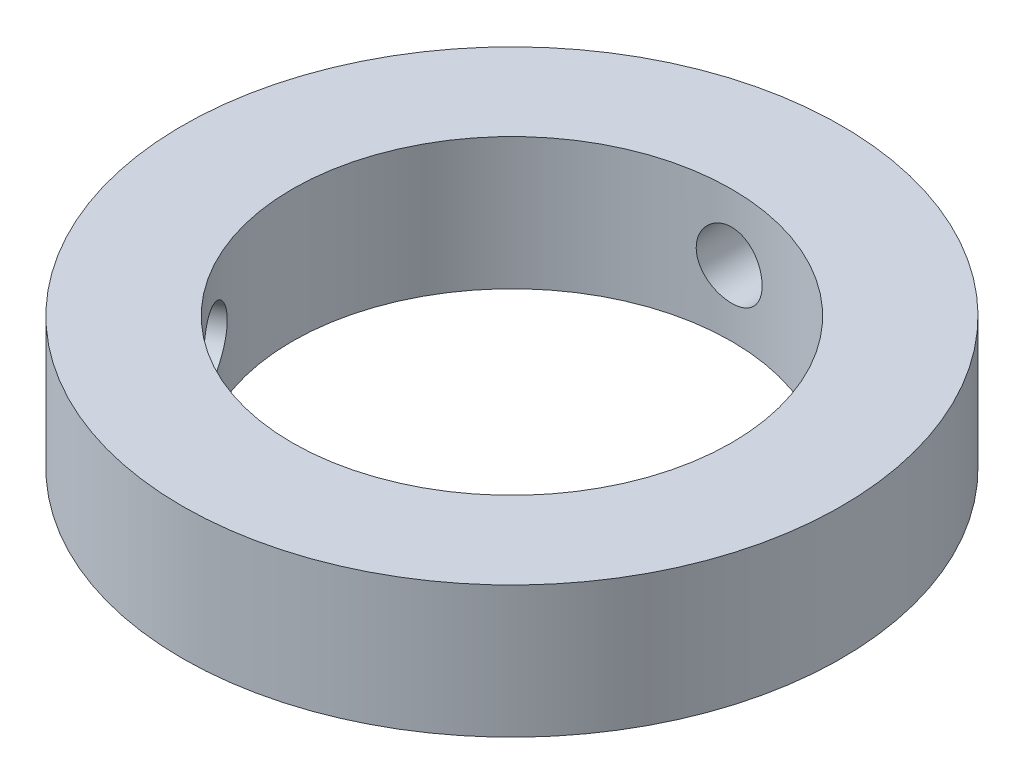
from build123d import *

# Parameters (mm, degrees)
SKETCH_1_R          = 15
SKETCH_1_R_2        = 10
EXTRUDE_1_DEPTH     = 6
CUT_EXTRUDE_1_REACH = 32
SKETCH_2_R          = 1.5
CUT_EXTRUDE_2_REACH = 37.49
SKETCH_3_R          = 1.5


with BuildPart() as part:
    # 스케치1 → 보스-돌출1 (new body)
    with BuildSketch(Plane(origin=(0, 0, 0), x_dir=(1, 0, 0), z_dir=(0, 1, 0))):
        Circle(SKETCH_1_R)
        Circle(SKETCH_1_R_2, mode=Mode.SUBTRACT)
    extrude(amount=EXTRUDE_1_DEPTH)

    # 스케치2 → 컷-돌출1 (cut, up to next)
    with BuildSketch(Plane(origin=(0, 0, -15), x_dir=(-1, 0, 0), z_dir=(0, 0, -1)), mode=Mode.PRIVATE) as cut_extrude_1_sk1:
        with Locations((0, 3)):
            Circle(SKETCH_2_R)
    cut_extrude_1_tool1 = extrude(cut_extrude_1_sk1.sketch, amount=-CUT_EXTRUDE_1_REACH, mode=Mode.PRIVATE) & part.part
    add(cut_extrude_1_tool1.solids().sort_by_distance((0, 3, -15))[0], mode=Mode.SUBTRACT)

    # 스케치3 → 컷-돌출2 (cut, up to next)
    with BuildSketch(Plane(origin=(-12.990381057, 0, 7.5), x_dir=(0, -1, 0), z_dir=(-0.866025404, 0, 0.5)), mode=Mode.PRIVATE) as cut_extrude_2_sk1:
        with Locations((-3, 0)):
            Circle(SKETCH_3_R)
    cut_extrude_2_tool1 = extrude(cut_extrude_2_sk1.sketch, amount=-CUT_EXTRUDE_2_REACH, mode=Mode.PRIVATE) & part.part
    add(cut_extrude_2_tool1.solids().sort_by_distance((-12.990381, 3, 7.5))[0], mode=Mode.SUBTRACT)


solid = part.part
